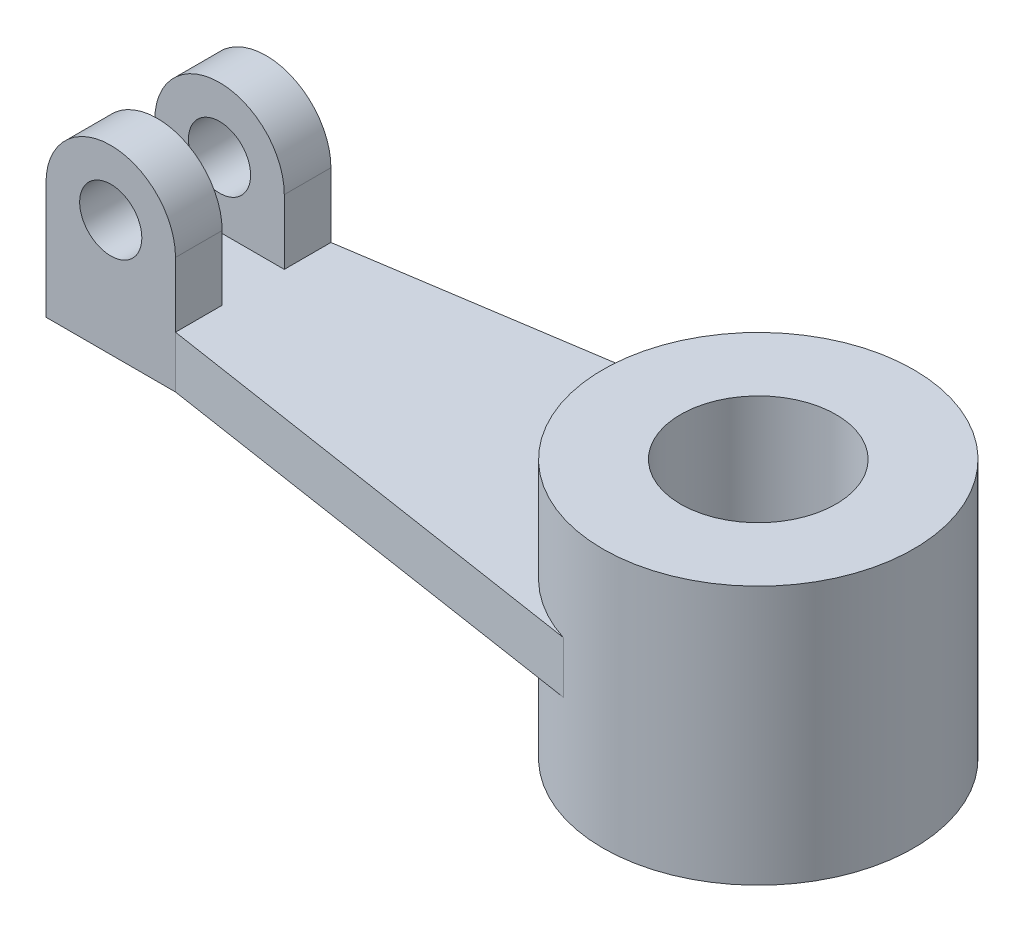
from build123d import *

# Parameters (mm, degrees)
SKETCH1_R           = 30
SKETCH1_R_2         = 15
BOSS_EXTRUDE2_DEPTH = 25
BOSS_EXTRUDE3_DEPTH = 5
BOSS_EXTRUDE5_DEPTH = 9
SKETCH6_R           = 6
BOSS_EXTRUDE6_DEPTH = 9
SKETCH7_R           = 6
CUT_EXTRUDE2_DEPTH  = 46


with BuildPart() as part:
    # Sketch1 → Boss-Extrude2 (new body, symmetric)
    with BuildSketch(Plane(origin=(0, 0, 0), x_dir=(1, 0, 0), z_dir=(0, 1, 0))):
        with Locations(Location((0, 0, 0), (0, 0, 270))):  # turned: the seam where the file's is
            Circle(SKETCH1_R)
        with Locations(Location((0, 0, 0), (0, 0, 270))):  # turned: the seam where the file's is
            Circle(SKETCH1_R_2, mode=Mode.SUBTRACT)
    extrude(amount=BOSS_EXTRUDE2_DEPTH, both=True)

    # Sketch3 → Boss-Extrude3 (add, symmetric)
    with BuildSketch(Plane(origin=(0, 0, 0), x_dir=(1, 0, 0), z_dir=(0, 1, 0))):
        with BuildLine():
            Line((-97.5, 15), (-122.5, 15))
            Line((-122.5, 15), (-122.5, -15))
            Line((-122.5, -15), (-97.5, -15))
            Line((-97.5, -15), (-9.01734104, -28.612716763))
            ThreePointArc((-9.01734104, -28.612716763), (-30, 0), (-9.01734104, 28.612716763))
            Line((-9.01734104, 28.612716763), (-97.5, 15))
        make_face()
    extrude(amount=BOSS_EXTRUDE3_DEPTH, both=True)

    # Sketch4 → Boss-Extrude5 (add)
    with BuildSketch(Plane.XY.offset(15)):
        with BuildLine():
            Line((-122.5, 5), (-122.5, 17.5))
            ThreePointArc((-122.5, 17.5), (-110, 30), (-97.5, 17.5))
            Line((-97.5, 17.5), (-97.5, 5))
            Line((-97.5, 5), (-97.5, -5))
            Line((-97.5, -5), (-122.5, -5))
            Line((-122.5, -5), (-122.5, 5))
        make_face()
    extrude(amount=-BOSS_EXTRUDE5_DEPTH)

    # Sketch6 → Boss-Extrude6 (add)
    with BuildSketch(Plane(origin=(0, 0, -15), x_dir=(-1, 0, 0), z_dir=(0, 0, -1))):
        with BuildLine():
            Line((97.5, 5), (97.5, 17.5))
            ThreePointArc((97.5, 17.5), (110, 30), (122.5, 17.5))
            Line((122.5, 17.5), (122.5, 5))
            Line((122.5, 5), (122.5, -5))
            Line((122.5, -5), (97.5, -5))
            Line((97.5, -5), (97.5, 5))
        make_face()
        with Locations((110, 17.5)):
            Circle(SKETCH6_R, mode=Mode.SUBTRACT)
    extrude(amount=-BOSS_EXTRUDE6_DEPTH)

    # Sketch7 → Cut-Extrude2 (cut, through all)
    with BuildSketch(Plane.XY.offset(15)):
        with Locations(Location((-110, 17.5, 0), (0, 0, 180))):  # turned: the seam where the file's is
            Circle(SKETCH7_R)
    extrude(amount=-CUT_EXTRUDE2_DEPTH, mode=Mode.SUBTRACT)


solid = part.part
